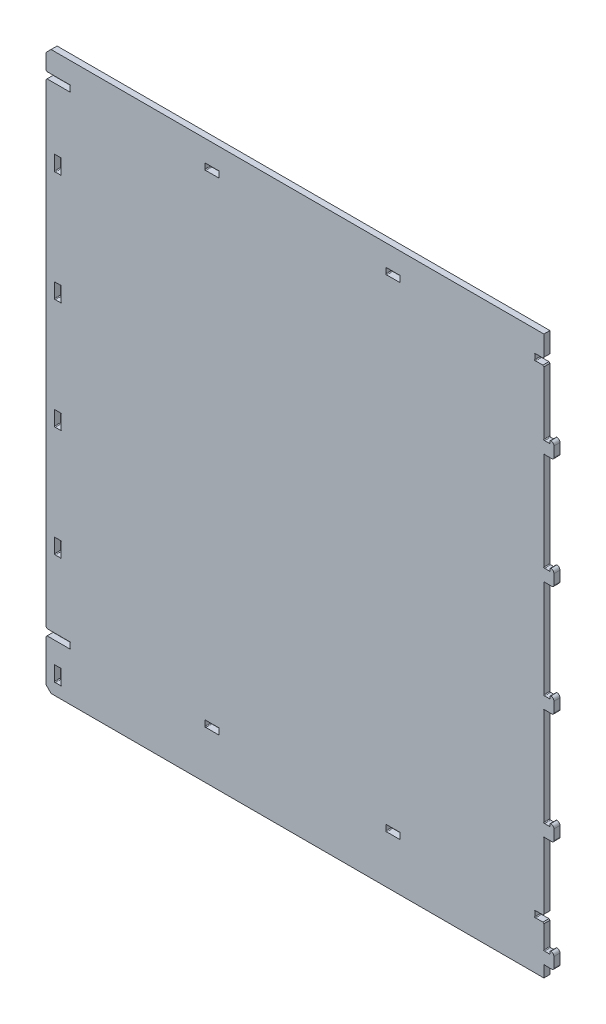
from build123d import *

# Parameters (mm, degrees)
SKETCH1_W                  = 495.4
SKETCH1_H                  = 555
BOSS_EXTRUDE1_DEPTH        = 6
BOSS_EXTRUDE2_DEPTH        = 6
SKETCH2_W                  = 6.5
SKETCH2_H                  = 15
CUT_EXTRUDE1_DEPTH         = 7
SKETCH6_R                  = 0.5
CUT_EXTRUDE4_DEPTH         = 7
LPATTERN1_COUNT            = 5
LPATTERN1_PITCH            = 110
SKETCH5_W                  = 24
SKETCH5_H                  = 6.2
SKETCH5_W_2                = 9
CUT_EXTRUDE3_DEPTH         = 6
SKETCH7_R                  = 0.5
CUT_EXTRUDE5_DEPTH         = 7
SKETCH8_W                  = 14
SKETCH8_H                  = 6.2
CUT_EXTRUDE6_DEPTH         = 7
SKETCH9_R                  = 0.5
CUT_EXTRUDE7_DEPTH         = 7
LPATTERN4_COUNT            = 2
LPATTERN4_PITCH            = 180
CHAMFER2_SIZE              = 1
LPATTERN3_COUNT            = 2
LPATTERN3_PITCH            = 480
LPATTERN3_COPY_1_SKETCH_W  = 14
LPATTERN3_COPY_1_SKETCH_H  = 6.2
LPATTERN3_COPY_1_DEPTH     = 7
LPATTERN3_COPY_2_SKETCH_R  = 0.5
LPATTERN3_COPY_2_DEPTH     = 7
CHAMFER2_OF_LPATTERN3_SIZE = 1
CHAMFER1_SIZE              = 5


with BuildPart() as part:
    # Sketch1 → Boss-Extrude1 (new body)
    with BuildSketch(Plane.XY):
        with Locations((247.7, 277.5)):
            Rectangle(SKETCH1_W, SKETCH1_H)
    extrude(amount=BOSS_EXTRUDE1_DEPTH)

    # Sketch3 → Boss-Extrude2 (add)
    with BuildSketch(Plane.XY.offset(6)):
        with BuildLine():
            Line((495.4, 23.500062699), (501.4, 23.500062699))
            Line((501.4, 23.500062699), (501.4, 25.500062699))
            ThreePointArc((501.4, 25.500062699), (501.692893219, 26.207169481), (502.4, 26.500062699))
            ThreePointArc((502.4, 26.500062699), (504.521320344, 25.621383043), (505.4, 23.500062699))
            Line((505.4, 23.500062699), (505.4, 13.5))
            ThreePointArc((505.4, 13.5), (504.814213562, 12.085786438), (503.4, 11.5))
            Line((503.4, 11.5), (495.4, 11.5))
            Line((495.4, 11.5), (495.4, 23.500062699))
        make_face()
    boss_extrude2 = extrude(amount=-BOSS_EXTRUDE2_DEPTH)

    # Sketch2 → Cut-Extrude1 (cut, through all)
    with BuildSketch(Plane.XY.offset(6)):
        with Locations((11.75, 19)):
            Rectangle(SKETCH2_W, SKETCH2_H)
    cut_extrude1 = extrude(amount=-CUT_EXTRUDE1_DEPTH, mode=Mode.SUBTRACT)

    # Sketch6 → Cut-Extrude4 (cut, through all)
    with BuildSketch(Plane.XY.offset(6)):
        with Locations((8.853553391, 11.853553391)):
            Circle(SKETCH6_R)
        with Locations((14.646446609, 11.853553391)):
            Circle(SKETCH6_R)
        with Locations((14.646446609, 26.146446609)):
            Circle(SKETCH6_R)
        with Locations((8.853553391, 26.146446609)):
            Circle(SKETCH6_R)
        with Locations((495.753553391, 23.85361609)):
            Circle(SKETCH6_R)
        with Locations((501.046446609, 23.85361609)):
            Circle(SKETCH6_R)
        with Locations((495.753553391, 11.146446609)):
            Circle(SKETCH6_R)
    cut_extrude4 = extrude(amount=-CUT_EXTRUDE4_DEPTH, mode=Mode.SUBTRACT)

    # LPattern1: Boss-Extrude2, Cut-Extrude1, Cut-Extrude4 ×5
    with Locations(*[(0, i * LPATTERN1_PITCH, 0) for i in range(1, LPATTERN1_COUNT)]):
        add(boss_extrude2)
        add(cut_extrude1, mode=Mode.SUBTRACT)
        add(cut_extrude4, mode=Mode.SUBTRACT)

    # Sketch5 → Cut-Extrude3 (cut)
    with BuildSketch(Plane.XY.offset(6)):
        with Locations((12, 50.8)):
            Rectangle(SKETCH5_W, SKETCH5_H)
        with Locations((490.9, 50.8)):
            Rectangle(SKETCH5_W_2, SKETCH5_H)
    cut_extrude3 = extrude(amount=-CUT_EXTRUDE3_DEPTH, mode=Mode.SUBTRACT)

    # Sketch7 → Cut-Extrude5 (cut, through all)
    with BuildSketch(Plane.XY.offset(6)):
        with Locations((486.753553391, 53.546446609)):
            Circle(SKETCH7_R)
        with Locations((486.753553391, 48.053553391)):
            Circle(SKETCH7_R)
        with Locations((23.646446609, 53.546446609)):
            Circle(SKETCH7_R)
        with Locations((23.646446609, 48.053553391)):
            Circle(SKETCH7_R)
    cut_extrude5 = extrude(amount=-CUT_EXTRUDE5_DEPTH, mode=Mode.SUBTRACT)

    # Sketch8 → Cut-Extrude6 (cut, through all)
    with BuildSketch(Plane.XY.offset(6)):
        with Locations((165.2, 50.8)):
            Rectangle(SKETCH8_W, SKETCH8_H)
    cut_extrude6 = extrude(amount=-CUT_EXTRUDE6_DEPTH, mode=Mode.SUBTRACT)

    # Sketch9 → Cut-Extrude7 (cut, through all)
    with BuildSketch(Plane.XY.offset(6)):
        with Locations((158.553553391, 53.546446609)):
            Circle(SKETCH9_R)
        with Locations((158.553553391, 48.053553391)):
            Circle(SKETCH9_R)
        with Locations((171.846446609, 48.053553391)):
            Circle(SKETCH9_R)
        with Locations((171.846446609, 53.546446609)):
            Circle(SKETCH9_R)
    cut_extrude7 = extrude(amount=-CUT_EXTRUDE7_DEPTH, mode=Mode.SUBTRACT)

    # LPattern4: Cut-Extrude6, Cut-Extrude7 ×2
    with Locations(*[(i * LPATTERN4_PITCH, 0, 0) for i in range(1, LPATTERN4_COUNT)]):
        add(cut_extrude6, mode=Mode.SUBTRACT)
        add(cut_extrude7, mode=Mode.SUBTRACT)

    # Chamfer2
    chamfer2_edges = [part.edges().sort_by_distance(p)[0] for p in [
        (0, 53.9, 3),
        (0, 47.7, 3),
        (495.4, 53.9, 3),
        (495.4, 47.7, 3),
    ]]
    chamfer(chamfer2_edges, length=CHAMFER2_SIZE)

    # LPattern3: Cut-Extrude3, Cut-Extrude5, Cut-Extrude6, Cut-Extrude7 ×2
    with Locations(*[(0, i * LPATTERN3_PITCH, 0) for i in range(1, LPATTERN3_COUNT)]):
        add(cut_extrude3, mode=Mode.SUBTRACT)
        add(cut_extrude5, mode=Mode.SUBTRACT)
        add(cut_extrude6, mode=Mode.SUBTRACT)
        add(cut_extrude7, mode=Mode.SUBTRACT)

    # LPattern3 copy 1 sketch → LPattern3 copy 1 (cut, through all)
    with BuildSketch(Plane(origin=(180, 480, 6), x_dir=(1, 0, 0), z_dir=(0, 0, 1))):
        with Locations((165.2, 50.8)):
            Rectangle(LPATTERN3_COPY_1_SKETCH_W, LPATTERN3_COPY_1_SKETCH_H)
    extrude(amount=-LPATTERN3_COPY_1_DEPTH, mode=Mode.SUBTRACT)

    # LPattern3 copy 2 sketch → LPattern3 copy 2 (cut, through all)
    with BuildSketch(Plane(origin=(180, 480, 6), x_dir=(1, 0, 0), z_dir=(0, 0, 1))):
        with Locations((158.553553391, 53.546446609)):
            Circle(LPATTERN3_COPY_2_SKETCH_R)
        with Locations((158.553553391, 48.053553391)):
            Circle(LPATTERN3_COPY_2_SKETCH_R)
        with Locations((171.846446609, 48.053553391)):
            Circle(LPATTERN3_COPY_2_SKETCH_R)
        with Locations((171.846446609, 53.546446609)):
            Circle(LPATTERN3_COPY_2_SKETCH_R)
    extrude(amount=-LPATTERN3_COPY_2_DEPTH, mode=Mode.SUBTRACT)

    # Chamfer2 of LPattern3
    chamfer2_of_lpattern3_edges = [part.edges().sort_by_distance(p)[0] for p in [
        (0, 533.9, 3),
        (0, 527.7, 3),
        (495.4, 533.9, 3),
        (495.4, 527.7, 3),
    ]]
    chamfer(chamfer2_of_lpattern3_edges, length=CHAMFER2_OF_LPATTERN3_SIZE)

    # Chamfer1
    chamfer1_edges = [part.edges().sort_by_distance(p)[0] for p in [
        (0, 555, 3),
        (0, 0, 3),
    ]]
    chamfer(chamfer1_edges, length=CHAMFER1_SIZE)


solid = part.part
